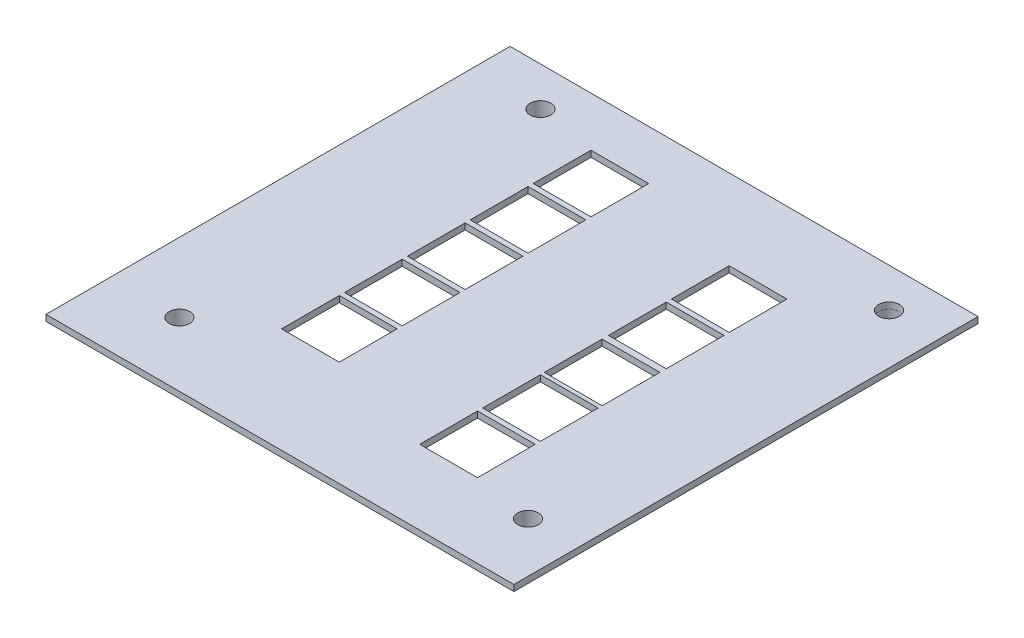
from build123d import *

# Parameters (mm, degrees)
SKETCH_1_W      = 45.369381955
SKETCH_1_H      = 45
SKETCH_1_R      = 1
SKETCH_1_W_2    = 5.6
SKETCH_1_H_2    = 5.6
EXTRUDE_1_DEPTH = 0.6
SKETCH_2_R      = 3.5
SKETCH_2_R_2    = 1
SKETCH_2_R_3    = 0.994011389
EXTRUDE_2_DEPTH = 1


with BuildPart() as part:
    # Эскиз1 → Бобышка-Вытянуть1 (new body)
    with BuildSketch(Plane(origin=(0, 0, 0), x_dir=(1, 0, 0), z_dir=(0, 1, 0))):
        with Locations((22.684690978, 22.5)):
            Rectangle(SKETCH_1_W, SKETCH_1_H)
        with Locations((6.737781955, 41.202537594)):
            Circle(SKETCH_1_R, mode=Mode.SUBTRACT)
        with Locations((40.537781955, 41.202537594)):
            Circle(SKETCH_1_R, mode=Mode.SUBTRACT)
        with Locations((40.537781955, 6.202537594)):
            Circle(SKETCH_1_R, mode=Mode.SUBTRACT)
        with Locations((6.737781955, 6.202537594)):
            Circle(SKETCH_1_R, mode=Mode.SUBTRACT)
        with Locations((15.437781955, 37.402537594)):
            Rectangle(SKETCH_1_W_2, SKETCH_1_H_2, mode=Mode.SUBTRACT)
        with Locations((15.437781955, 31.302537594)):
            Rectangle(SKETCH_1_W_2, SKETCH_1_H_2, mode=Mode.SUBTRACT)
        with Locations((15.437781955, 25.202537594)):
            Rectangle(SKETCH_1_W_2, SKETCH_1_H_2, mode=Mode.SUBTRACT)
        with Locations((15.437781955, 19.102537594)):
            Rectangle(SKETCH_1_W_2, SKETCH_1_H_2, mode=Mode.SUBTRACT)
        with Locations((15.437781955, 13.002237594)):
            Rectangle(SKETCH_1_W_2, SKETCH_1_H_2, mode=Mode.SUBTRACT)
        with Locations((31.837781955, 10.002237594)):
            Rectangle(SKETCH_1_W_2, SKETCH_1_H_2, mode=Mode.SUBTRACT)
        with Locations((31.837781955, 16.102237594)):
            Rectangle(SKETCH_1_W_2, SKETCH_1_H_2, mode=Mode.SUBTRACT)
        with Locations((31.837781955, 22.087504722)):
            Rectangle(SKETCH_1_W_2, SKETCH_1_H_2, mode=Mode.SUBTRACT)
        with Locations((31.837781955, 28.302237594)):
            Rectangle(SKETCH_1_W_2, SKETCH_1_H_2, mode=Mode.SUBTRACT)
        with Locations((31.837781955, 34.402237594)):
            Rectangle(SKETCH_1_W_2, SKETCH_1_H_2, mode=Mode.SUBTRACT)
    extrude(amount=EXTRUDE_1_DEPTH)

    # Эскиз2 → Бобышка-Вытянуть2 (add)
    with BuildSketch(Plane.XZ):
        with Locations((6.737781955, -6.202537594)):
            Circle(SKETCH_2_R)
        with Locations((6.737781955, -6.202537594)):
            Circle(SKETCH_2_R_2, mode=Mode.SUBTRACT)
        with Locations((40.537781955, -6.202537594)):
            Circle(SKETCH_2_R)
        with Locations((40.537781955, -6.202537594)):
            Circle(SKETCH_2_R_2, mode=Mode.SUBTRACT)
        with Locations((40.537781955, -41.202537594)):
            Circle(SKETCH_2_R)
        with Locations((40.537781955, -41.202537594)):
            Circle(SKETCH_2_R_3, mode=Mode.SUBTRACT)
        with Locations((6.737781955, -41.202537594)):
            Circle(SKETCH_2_R)
        with Locations((6.737781955, -41.202537594)):
            Circle(SKETCH_2_R_2, mode=Mode.SUBTRACT)
    extrude(amount=EXTRUDE_2_DEPTH)


solid = part.part
